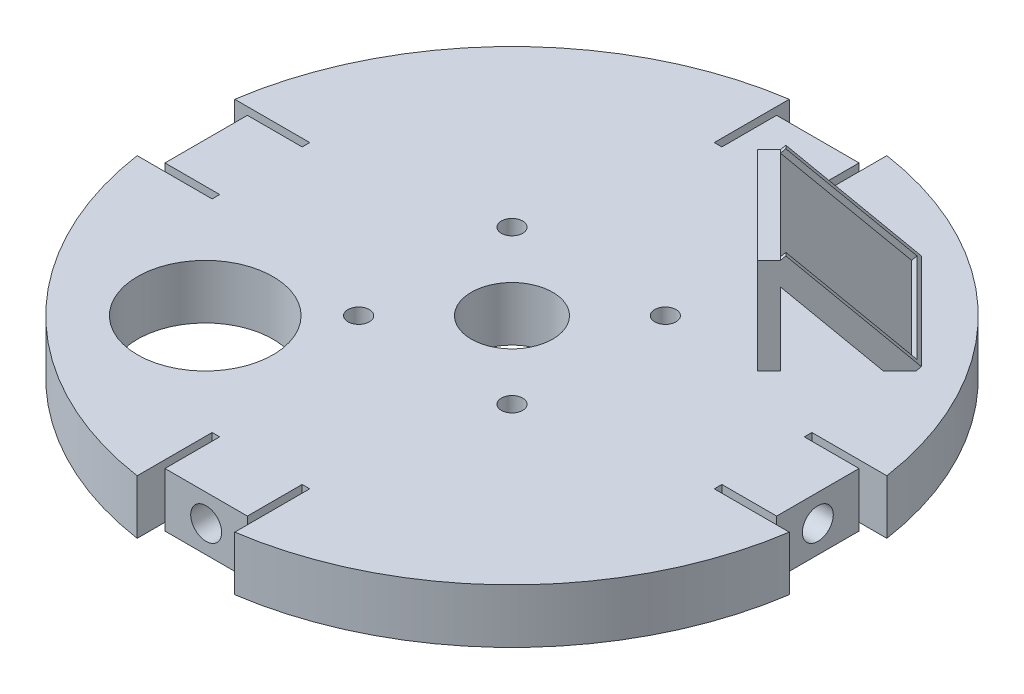
from build123d import *

# Parameters (mm, degrees)
SKETCH2_W            = 67.691
SKETCH2_H            = 12.7
SKETCH3_R            = 2.5019
CUT_EXTRUDE1_DEPTH   = 13.7
LPATTERN1_COUNT      = 2
LPATTERN1_PITCH      = 35.921024484
LPATTERN1_COUNT_DIR2 = 2
LPATTERN1_PITCH_DIR2 = 35.921024484
SKETCH5_R            = 15.875
CUT_EXTRUDE2_DEPTH   = 13.7
BOSS_EXTRUDE1_DEPTH  = 15.875
BOSS_EXTRUDE2_DEPTH  = 1.27
CUT_EXTRUDE3_DEPTH   = 13.7
SKETCH13_R           = 4.8387
CUT_EXTRUDE4_DEPTH   = 3.81
SKETCH14_R           = 3.6195
CUT_EXTRUDE5_DEPTH   = 5.715
CUT_EXTRUDE6_DEPTH   = 13.7000001
SKETCH16_R           = 2.413
CUT_EXTRUDE7_DEPTH   = 2.54
CIRPATTERN2_COUNT    = 4


with BuildPart() as part:
    # Sketch2 → Revolve1 (revolve)
    with BuildSketch(Plane(origin=(0, 0, 0), x_dir=(0, 0, -1), z_dir=(1, 0, 0))):
        with Locations((43.3705, 0)):
            Rectangle(SKETCH2_W, SKETCH2_H)
    revolve(axis=Axis((0, 9.434285714, 0), (0, -1, 0)))

    # Sketch3 → Cut-Extrude1 (cut, through all)
    with BuildSketch(Plane(origin=(0, 6.35, 0), x_dir=(1, 0, 0), z_dir=(0, 1, 0))):
        with Locations((17.960512242, 17.960512242)):
            Circle(SKETCH3_R)
    cut_extrude1 = extrude(amount=-CUT_EXTRUDE1_DEPTH, mode=Mode.SUBTRACT)

    # LPattern1: Cut-Extrude1 2 × 2
    with Locations(*[(-j * LPATTERN1_PITCH_DIR2, 0, i * LPATTERN1_PITCH) for i in range(LPATTERN1_COUNT) for j in range(LPATTERN1_COUNT_DIR2) if (i, j) != (0, 0)]):
        add(cut_extrude1, mode=Mode.SUBTRACT)

    # Sketch5 → Cut-Extrude2 (cut, through all)
    with BuildSketch(Plane(origin=(0, 6.35, 0), x_dir=(1, 0, 0), z_dir=(0, 1, 0))):
        with Locations((-35.921024484, -35.921024484)):
            Circle(SKETCH5_R)
    extrude(amount=-CUT_EXTRUDE2_DEPTH, mode=Mode.SUBTRACT)

    # Sketch7 → Boss-Extrude1 (add, symmetric)
    with BuildSketch(Plane(origin=(0, 0, 0), x_dir=(0.707106781, 0, -0.707106781), z_dir=(0.707106781, 0, 0.707106781))):
        Polygon((66.900640303, 6.35), (44.45, 28.800640303), (40.64, 28.800640303), (40.64, 6.35), (44.45, 6.35), (44.45, 23.41248663), (61.51248663, 6.35), align=None)
    extrude(amount=BOSS_EXTRUDE1_DEPTH, both=True)

    # Sketch8 → Boss-Extrude2 (add, symmetric)
    with BuildSketch(Plane(origin=(25.898012242, 36.625320151, -25.898012242), x_dir=(0.866025404, -0.40824829, 0.288675135), z_dir=(0.5, 0.707106781, -0.5))):
        Polygon((37.681578612, 25.793492955), (11.757812168, 44.124364002), (-6.573058879, 18.200597557), (-5.743498353, 17.614009684), (-5.156910479, 18.44357021), (12.000784821, 42.708215602), (36.265430213, 25.550520302), (19.107734913, 1.28587491), (18.521147039, 0.456314384), (19.350707566, -0.130273489), align=None)
    extrude(amount=BOSS_EXTRUDE2_DEPTH, both=True)

    # Sketch12 → Cut-Extrude3 (cut, through all)
    with BuildSketch(Plane(origin=(0, 6.35, 0), x_dir=(1, 0, 0), z_dir=(0, 1, 0))):
        Polygon((73.406, -11.43), (58.801, -11.43), (58.801, -9.652), (71.628, -9.652), (71.628, 9.652), (58.801, 9.652), (58.801, 11.43), (73.406, 11.43), align=None)
    cut_extrude3 = extrude(amount=-CUT_EXTRUDE3_DEPTH, mode=Mode.SUBTRACT)

    # Sketch13 → Cut-Extrude4 (cut)
    with BuildSketch(Plane(origin=(77.216, 0, 0), x_dir=(0, 0, -1), z_dir=(1, 0, 0))):
        Circle(SKETCH13_R)
    cut_extrude4 = extrude(amount=-CUT_EXTRUDE4_DEPTH, mode=Mode.SUBTRACT)

    # Sketch14 → Cut-Extrude5 (cut)
    with BuildSketch(Plane(origin=(71.628, 0, 0), x_dir=(0, 0, -1), z_dir=(1, 0, 0))):
        Circle(SKETCH14_R)
    cut_extrude5 = extrude(amount=-CUT_EXTRUDE5_DEPTH, mode=Mode.SUBTRACT)

    # Sketch15 → Cut-Extrude6 (cut, through all)
    with BuildSketch(Plane(origin=(0, 6.35, 0), x_dir=(1, 0, 0), z_dir=(0, 1, 0))):
        with BuildLine():
            Line((73.406, 11.43), (76.365343946, 11.43))
            ThreePointArc((76.365343946, 11.43), (77.216, 0), (76.365343946, -11.43))
            Line((76.365343946, -11.43), (73.406, -11.43))
            Line((73.406, -11.43), (73.406, 11.43))
        make_face()
    cut_extrude6 = extrude(amount=-CUT_EXTRUDE6_DEPTH, mode=Mode.SUBTRACT)

    # Sketch16 → Cut-Extrude7 (cut)
    with BuildSketch(Plane(origin=(65.913, 0, 0), x_dir=(0, 0, -1), z_dir=(1, 0, 0))):
        Circle(SKETCH16_R)
    cut_extrude7 = extrude(amount=-CUT_EXTRUDE7_DEPTH, mode=Mode.SUBTRACT)

    # CirPattern2: Cut-Extrude3, Cut-Extrude4, Cut-Extrude5, Cut-Extrude6, Cut-Extrude7 ×4 about axis
    cirpattern2_axis = Axis((0, 0, 0), (0, 1, 0))
    for i in range(1, CIRPATTERN2_COUNT):
        add(cut_extrude3.rotate(cirpattern2_axis, i * 360 / CIRPATTERN2_COUNT), mode=Mode.SUBTRACT)
        add(cut_extrude4.rotate(cirpattern2_axis, i * 360 / CIRPATTERN2_COUNT), mode=Mode.SUBTRACT)
        add(cut_extrude5.rotate(cirpattern2_axis, i * 360 / CIRPATTERN2_COUNT), mode=Mode.SUBTRACT)
        add(cut_extrude6.rotate(cirpattern2_axis, i * 360 / CIRPATTERN2_COUNT), mode=Mode.SUBTRACT)
        add(cut_extrude7.rotate(cirpattern2_axis, i * 360 / CIRPATTERN2_COUNT), mode=Mode.SUBTRACT)


solid = part.part
